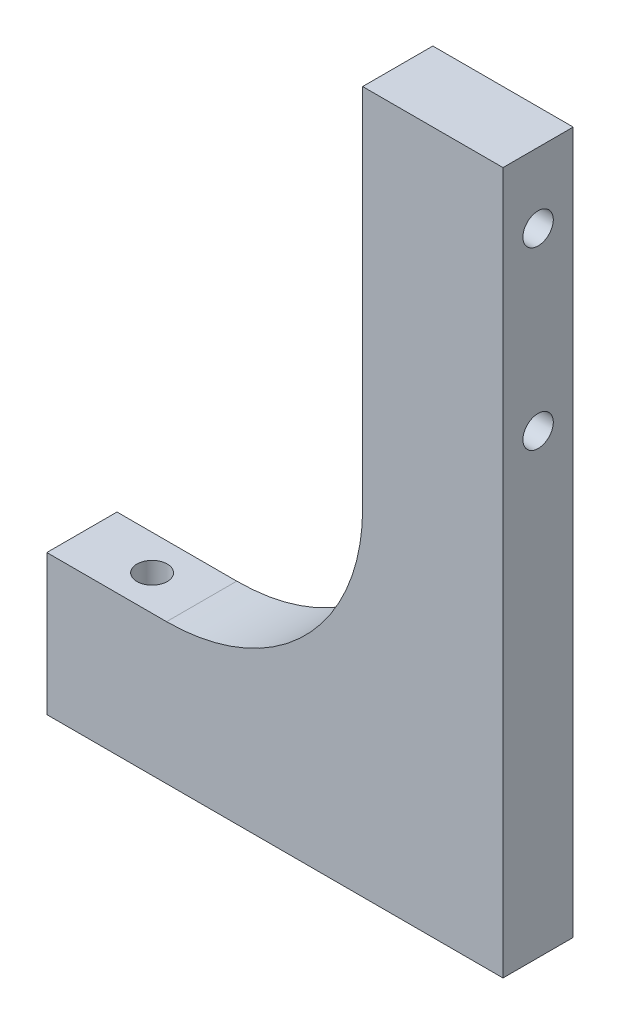
from build123d import *

# Parameters (mm, degrees)
BOSS_EXTRUDE1_DEPTH   = 25.4
M10_CLEARANCE_HOLE1_D = 11
M10_CLEARANCE_HOLE2_D = 11
FILLET1_R             = 70.96


with BuildPart() as part:
    # Sketch1 → Boss-Extrude1 (new body)
    with BuildSketch(Plane.XY):
        Polygon((0, 194.731808123), (0, -59.268191877), (-165.1, -59.268191877), (-165.1, -8.468191877), (-50.8, -8.468191877), (-50.8, 194.731808123), align=None)
    extrude(amount=BOSS_EXTRUDE1_DEPTH)

    # M10 Clearance Hole1 (through all)
    with Locations(Plane(origin=(0, -8.468191877, 0), x_dir=(1, 0, 0), z_dir=(0, 1, 0))):
        with Locations((-139.7, -12.7)):
            Hole(M10_CLEARANCE_HOLE1_D / 2)

    # M10 Clearance Hole2 (through all)
    with Locations(Plane.ZY.offset(50.8)):
        with Locations((12.7, 169.331808123), (12.7, 105.831808123)):
            Hole(M10_CLEARANCE_HOLE2_D / 2)

    # Fillet1
    fillet1_edges = [part.edges().sort_by_distance(p)[0] for p in [
        (-50.8, -8.468191877, 12.7),
    ]]
    fillet(fillet1_edges, radius=FILLET1_R)


solid = part.part
